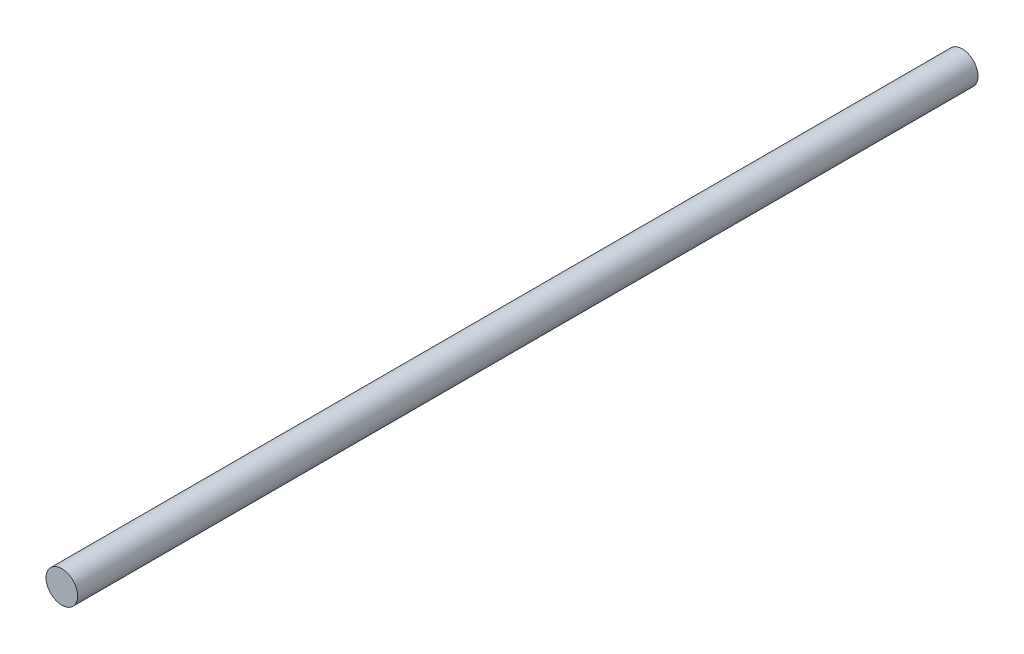
from build123d import *

# Parameters (mm, degrees)
SKETCH1_R           = 4
BOSS_EXTRUDE1_DEPTH = 287.5
SKETCH2_R           = 4
BOSS_EXTRUDE2_DEPTH = 45
SKETCH3_R           = 4
CUT_EXTRUDE1_DEPTH  = 105


with BuildPart() as part:
    # Sketch1 → Boss-Extrude1 (new body)
    with BuildSketch(Plane.XY):
        Circle(SKETCH1_R)
    extrude(amount=BOSS_EXTRUDE1_DEPTH)

    # Sketch2 → Boss-Extrude2 (add)
    with BuildSketch(Plane.XY.offset(287.5)):
        Circle(SKETCH2_R)
    extrude(amount=BOSS_EXTRUDE2_DEPTH)

    # Sketch3 → Cut-Extrude1 (cut)
    with BuildSketch(Plane(origin=(0, 0, 0), x_dir=(-1, 0, 0), z_dir=(0, 0, -1))):
        Circle(SKETCH3_R)
    extrude(amount=-CUT_EXTRUDE1_DEPTH, mode=Mode.SUBTRACT)


solid = part.part
